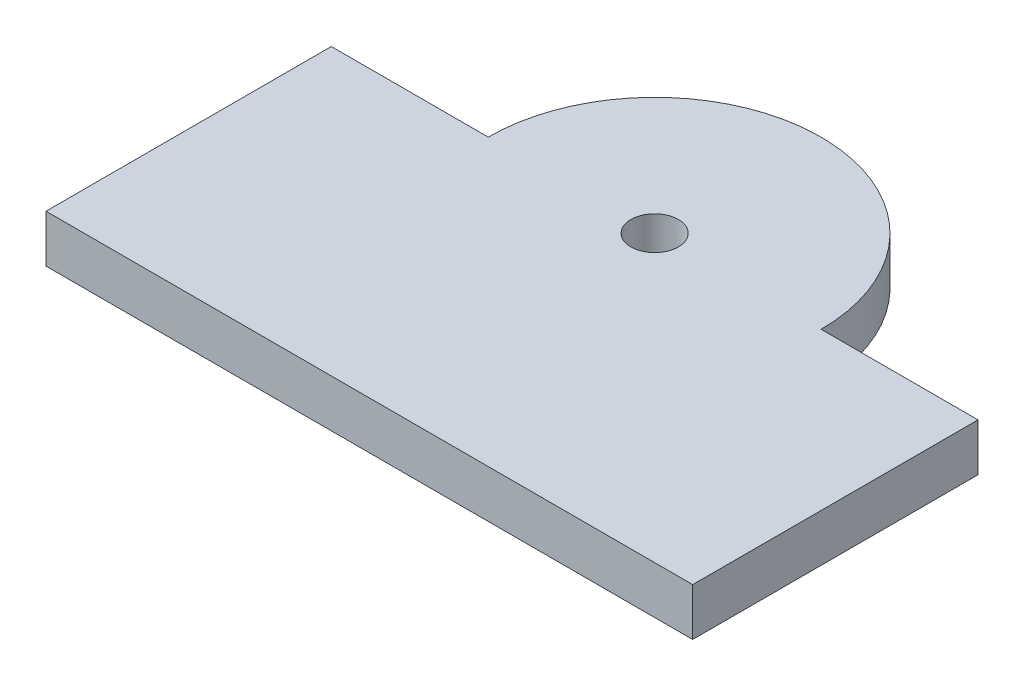
from build123d import *

# Parameters (mm, degrees)
SKETCH1_W               = 68
SKETCH1_H               = 30
BOSS_EXTRUDE1_DEPTH     = 5
SKETCH2_R               = 17.5
BOSS_EXTRUDE2_DEPTH     = 5
SKETCH3_R               = 2.5
CUT_EXTRUDE1_DEPTH      = 1
CUT_EXTRUDE1_DEPTH_BACK = 6


with BuildPart() as part:
    # Sketch1 → Boss-Extrude1 (new body)
    with BuildSketch(Plane(origin=(0, 0, 0), x_dir=(1, 0, 0), z_dir=(0, 1, 0))):
        Rectangle(SKETCH1_W, SKETCH1_H)
    extrude(amount=BOSS_EXTRUDE1_DEPTH)

    # Sketch2 → Boss-Extrude2 (add)
    with BuildSketch(Plane(origin=(0, 5, 0), x_dir=(1, 0, 0), z_dir=(0, 1, 0))):
        with Locations((0, 15)):
            Circle(SKETCH2_R)
    extrude(amount=-BOSS_EXTRUDE2_DEPTH)

    # Sketch3 → Cut-Extrude1 (cut, two sides)
    with BuildSketch(Plane(origin=(0, 5, 0), x_dir=(1, 0, 0), z_dir=(0, 1, 0))) as cut_extrude1_sk:
        with Locations((0, 15)):
            Circle(SKETCH3_R)
    extrude(amount=CUT_EXTRUDE1_DEPTH, mode=Mode.SUBTRACT)
    extrude(cut_extrude1_sk.sketch, amount=-CUT_EXTRUDE1_DEPTH_BACK, mode=Mode.SUBTRACT)


solid = part.part
